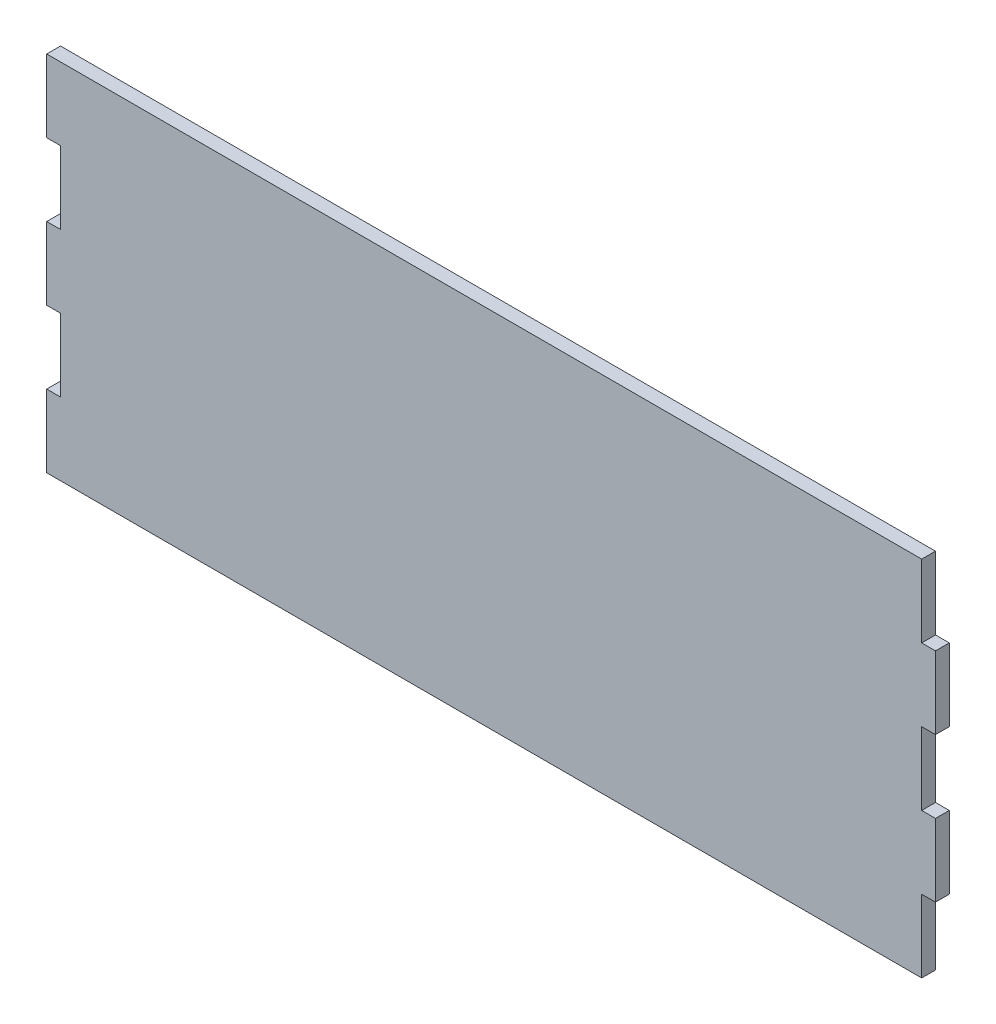
from build123d import *

# Parameters (mm, degrees)
BOSS_EXTRUDE1_DEPTH = 4.826


with BuildPart() as part:
    # Sketch1 → Boss-Extrude1 (new body)
    with BuildSketch(Plane.XY):
        Polygon((617.474, 25.4), (617.474, 0), (311.15, 0), (311.15, 25.4), (315.976, 25.4), (315.976, 50.8), (311.15, 50.8), (311.15, 76.2), (315.976, 76.2), (315.976, 101.6), (311.15, 101.6), (311.15, 127), (617.474, 127), (617.474, 101.6), (622.3, 101.6), (622.3, 76.2), (617.474, 76.2), (617.474, 50.8), (622.3, 50.8), (622.3, 25.4), align=None)
    extrude(amount=BOSS_EXTRUDE1_DEPTH)


solid = part.part
